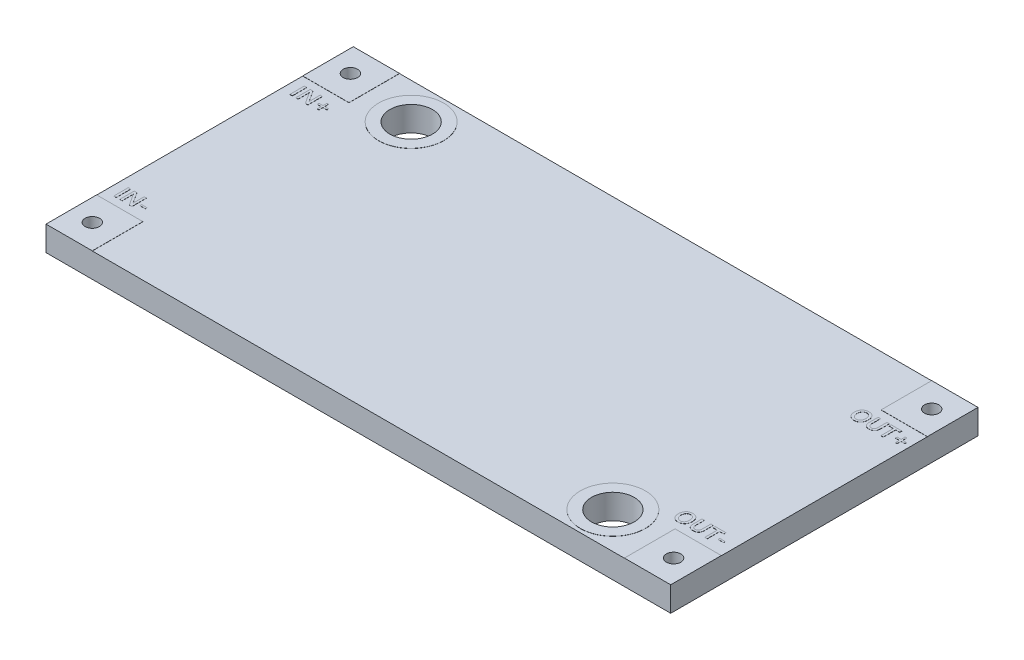
from build123d import *

# Parameters (mm, degrees)
SKETCH1_W           = 43.2
SKETCH1_H           = 21.25
BOSS_EXTRUDE1_DEPTH = 1.7
SKETCH2_R           = 1.475
SKETCH2_R_2         = 0.5
CUT_EXTRUDE1_DEPTH  = 25.131734811
SKETCH3_R           = 2.25
SKETCH3_R_2         = 1.475
SKETCH3_W           = 3.2
SKETCH3_H           = 3.5
SKETCH3_R_3         = 0.5
BOSS_EXTRUDE2_DEPTH = 0.01
SKETCH4_W           = 0.170024671
SKETCH4_H           = 1
SKETCH4_W_2         = 0.37890625
SKETCH4_H_2         = 0.118421053
BOSS_EXTRUDE3_DEPTH = 0.01


with BuildPart() as part:
    # Sketch1 → Boss-Extrude1 (new body)
    with BuildSketch(Plane(origin=(0, 0, 0), x_dir=(1, 0, 0), z_dir=(0, 1, 0))):
        Rectangle(SKETCH1_W, SKETCH1_H)
    extrude(amount=BOSS_EXTRUDE1_DEPTH)

    # Sketch2 → Cut-Extrude1 (cut, through all)
    with BuildSketch(Plane(origin=(0, 0, 0), x_dir=(1, 0, 0), z_dir=(0, 1, 0))):
        with Locations(Location((-15.1, 8.125, 0), (0, 0, 270))):
            Circle(SKETCH2_R)
        with Locations(Location((-20.1, 8.925, 0), (0, 0, 270))):
            Circle(SKETCH2_R_2)
        with Locations(Location((15.1, -8.125, 0), (0, 0, 270))):
            Circle(SKETCH2_R)
        with Locations(Location((20.1, -8.925, 0), (0, 0, 270))):
            Circle(SKETCH2_R_2)
        with Locations(Location((20.1, 8.925, 0), (0, 0, 90))):
            Circle(SKETCH2_R_2)
        with Locations(Location((-20.1, -8.925, 0), (0, 0, 90))):
            Circle(SKETCH2_R_2)
    extrude(amount=CUT_EXTRUDE1_DEPTH, mode=Mode.SUBTRACT)

    # Sketch3 → Boss-Extrude2 (add)
    with BuildSketch(Plane(origin=(0, 1.7, 0), x_dir=(1, 0, 0), z_dir=(0, 1, 0))):
        with Locations(Location((-15.1, 8.125, 0), (0, 0, 90))):
            Circle(SKETCH3_R)
        with Locations(Location((-15.1, 8.125, 0), (0, 0, 270))):
            Circle(SKETCH3_R_2, mode=Mode.SUBTRACT)
        with Locations(Location((15.1, -8.125, 0), (0, 0, 90))):
            Circle(SKETCH3_R)
        with Locations(Location((15.1, -8.125, 0), (0, 0, 270))):
            Circle(SKETCH3_R_2, mode=Mode.SUBTRACT)
        with Locations((-20, 8.875)):
            Rectangle(SKETCH3_W, SKETCH3_H)
        with Locations(Location((-20.1, 8.925, 0), (0, 0, 270))):
            Circle(SKETCH3_R_3, mode=Mode.SUBTRACT)
        with Locations((-20, -8.875)):
            Rectangle(SKETCH3_W, SKETCH3_H)
        with Locations(Location((-20.1, -8.925, 0), (0, 0, 90))):
            Circle(SKETCH3_R_3, mode=Mode.SUBTRACT)
        with Locations((20, -8.875)):
            Rectangle(SKETCH3_W, SKETCH3_H)
        with Locations(Location((20.1, -8.925, 0), (0, 0, 270))):
            Circle(SKETCH3_R_3, mode=Mode.SUBTRACT)
        with Locations((20, 8.875)):
            Rectangle(SKETCH3_W, SKETCH3_H)
        with Locations(Location((20.1, 8.925, 0), (0, 0, 90))):
            Circle(SKETCH3_R_3, mode=Mode.SUBTRACT)
    extrude(amount=BOSS_EXTRUDE2_DEPTH)

    # Sketch4 → Boss-Extrude3 (add)
    with BuildSketch(Plane(origin=(0, 1.7, 0), x_dir=(1, 0, 0), z_dir=(0, 1, 0))):
        with Locations((-20.852438923, 6.075899594)):
            Rectangle(SKETCH4_W, SKETCH4_H)
        with BuildLine():
            Line((-19.685189745, 5.575899594), (-19.865494021, 5.575899594))
            Line((-19.865494021, 5.575899594), (-20.340822969, 6.31089137))
            add(Edge.make_bspline(
                [(-20.340822969, 6.31089137), (-20.34654146, 6.320295921), (-20.357860845, 6.338911621), (-20.366405755, 6.358952171), (-20.370633824, 6.368868344)],
                knots=[0, 0, 0, 0, 1.010389057, 2, 2, 2, 2], degree=3))
            Line((-20.370633824, 6.368868344), (-20.374745666, 6.368868344))
            add(Edge.make_bspline(
                [(-20.374745666, 6.368868344), (-20.374325341, 6.365785885), (-20.373392772, 6.358946868), (-20.372063704, 6.347515569), (-20.371450169, 6.333779731), (-20.3705252, 6.317752766), (-20.369949118, 6.299449662), (-20.369617758, 6.278819113), (-20.369072437, 6.255932042), (-20.369152789, 6.23989393), (-20.369194679, 6.231532818)],
                knots=[0, 0, 0, 0, 0.542850591, 1.204416297, 2.006997007, 2.940909611, 4.005733812, 5.201725499, 6.541181877, 8, 8, 8, 8], degree=3))
            Line((-20.369194679, 6.231532818), (-20.369194679, 5.575899594))
            Line((-20.369194679, 5.575899594), (-20.528939745, 5.575899594))
            Line((-20.528939745, 5.575899594), (-20.528939745, 6.575899594))
            Line((-20.528939745, 6.575899594), (-20.336711126, 6.575899594))
            Line((-20.336711126, 6.575899594), (-19.877212771, 5.858383147))
            add(Edge.make_bspline(
                [(-19.877212771, 5.858383147), (-19.872803757, 5.851544578), (-19.86472599, 5.839015618), (-19.85411523, 5.821873507), (-19.845964808, 5.808266036), (-19.841625663, 5.800280254), (-19.839795008, 5.796911107)],
                knots=[0, 0, 0, 0, 1.356381881, 2.48503099, 3.360844982, 4, 4, 4, 4], degree=3))
            Line((-19.839795008, 5.796911107), (-19.837122311, 5.796911107))
            add(Edge.make_bspline(
                [(-19.837122311, 5.796911107), (-19.83771686, 5.8004688), (-19.839004079, 5.808171316), (-19.840032502, 5.820758925), (-19.841330637, 5.835000209), (-19.842409475, 5.85096876), (-19.842850435, 5.868663676), (-19.843639937, 5.888119478), (-19.843671104, 5.909302235), (-19.843826334, 5.923967309), (-19.84390685, 5.931573936)],
                knots=[0, 0, 0, 0, 0.641182925, 1.388181035, 2.244403229, 3.184783092, 4.233507647, 5.391855368, 6.647181581, 8, 8, 8, 8], degree=3))
            Line((-19.84390685, 5.931573936), (-19.84390685, 6.575899594))
            Line((-19.84390685, 6.575899594), (-19.685189745, 6.575899594))
            Line((-19.685189745, 6.575899594), (-19.685189745, 5.575899594))
        make_face()
        Polygon((-18.731653561, 5.931162752), (-19.005707837, 5.931162752), (-19.005707837, 5.654846962), (-19.12022264, 5.654846962), (-19.12022264, 5.931162752), (-19.394276916, 5.931162752), (-19.394276916, 6.049583805), (-19.12022264, 6.049583805), (-19.12022264, 6.325899594), (-19.005707837, 6.325899594), (-19.005707837, 6.049583805), (-18.731653561, 6.049583805), align=None)
        with Locations((-20.852438923, -6.097777607)):
            Rectangle(SKETCH4_W, SKETCH4_H)
        with BuildLine():
            Line((-19.685189745, -6.597777607), (-19.865494021, -6.597777607))
            Line((-19.865494021, -6.597777607), (-20.340822969, -5.862785831))
            add(Edge.make_bspline(
                [(-20.340822969, -5.862785831), (-20.34654146, -5.853381281), (-20.357860845, -5.83476558), (-20.366405755, -5.814725031), (-20.370633824, -5.804808857)],
                knots=[0, 0, 0, 0, 1.010389057, 2, 2, 2, 2], degree=3))
            Line((-20.370633824, -5.804808857), (-20.374745666, -5.804808857))
            add(Edge.make_bspline(
                [(-20.374745666, -5.804808857), (-20.374325341, -5.807891316), (-20.373392772, -5.814730333), (-20.372063704, -5.826161632), (-20.371450169, -5.83989747), (-20.3705252, -5.855924436), (-20.369949118, -5.87422754), (-20.369617758, -5.894858089), (-20.369072437, -5.917745159), (-20.369152789, -5.933783271), (-20.369194679, -5.942144384)],
                knots=[0, 0, 0, 0, 0.542850591, 1.204416297, 2.006997007, 2.940909611, 4.005733812, 5.201725499, 6.541181877, 8, 8, 8, 8], degree=3))
            Line((-20.369194679, -5.942144384), (-20.369194679, -6.597777607))
            Line((-20.369194679, -6.597777607), (-20.528939745, -6.597777607))
            Line((-20.528939745, -6.597777607), (-20.528939745, -5.597777607))
            Line((-20.528939745, -5.597777607), (-20.336711126, -5.597777607))
            Line((-20.336711126, -5.597777607), (-19.877212771, -6.315294055))
            add(Edge.make_bspline(
                [(-19.877212771, -6.315294055), (-19.872803757, -6.322132623), (-19.86472599, -6.334661583), (-19.85411523, -6.351803695), (-19.845964808, -6.365411166), (-19.841625663, -6.373396948), (-19.839795008, -6.376766094)],
                knots=[0, 0, 0, 0, 1.356381881, 2.48503099, 3.360844982, 4, 4, 4, 4], degree=3))
            Line((-19.839795008, -6.376766094), (-19.837122311, -6.376766094))
            add(Edge.make_bspline(
                [(-19.837122311, -6.376766094), (-19.83771686, -6.373208401), (-19.839004079, -6.365505886), (-19.840032502, -6.352918277), (-19.841330637, -6.338676992), (-19.842409475, -6.322708442), (-19.842850435, -6.305013525), (-19.843639937, -6.285557723), (-19.843671104, -6.264374967), (-19.843826334, -6.249709892), (-19.84390685, -6.242103265)],
                knots=[0, 0, 0, 0, 0.641182925, 1.388181035, 2.244403229, 3.184783092, 4.233507647, 5.391855368, 6.647181581, 8, 8, 8, 8], degree=3))
            Line((-19.84390685, -6.242103265), (-19.84390685, -5.597777607))
            Line((-19.84390685, -5.597777607), (-19.685189745, -5.597777607))
            Line((-19.685189745, -5.597777607), (-19.685189745, -6.597777607))
        make_face()
        with Locations((-19.27020208, -6.209619713)):
            Rectangle(SKETCH4_W_2, SKETCH4_H_2)
        with BuildLine():
            add(Edge.make_bspline(
                [(18.082538877, 5.562741699), (18.065044998, 5.563194363), (18.030828975, 5.564079722), (17.980815608, 5.570465796), (17.933499786, 5.581360524), (17.888833922, 5.596613073), (17.84675845, 5.616178356), (17.8075888, 5.640458261), (17.770862125, 5.668768002), (17.737315693, 5.701416599), (17.707239746, 5.737566169), (17.680667293, 5.776359769), (17.658435613, 5.817987884), (17.640031245, 5.862161287), (17.625885134, 5.909016789), (17.61584568, 5.958428037), (17.609819326, 6.010440216), (17.609044893, 6.046003971), (17.608649075, 6.064180844)],
                knots=[0, 0, 0, 0, 1.080688534, 2.113702916, 3.108931422, 4.075669577, 5.024646271, 5.969410339, 6.917101566, 7.884256872, 8.855186167, 9.818171139, 10.784287868, 11.765612141, 12.770163835, 13.803152185, 14.877176389, 16, 16, 16, 16], degree=3))
            add(Edge.make_bspline(
                [(17.608649075, 6.064180844), (17.60902151, 6.083661091), (17.609748676, 6.121695593), (17.616070295, 6.177248847), (17.626175781, 6.229769327), (17.64064918, 6.279255719), (17.659134947, 6.325816033), (17.682007984, 6.369262503), (17.708947669, 6.409707591), (17.739745804, 6.446846772), (17.773991489, 6.480446284), (17.811624929, 6.509586269), (17.8522784, 6.534202395), (17.895794961, 6.554512682), (17.942463245, 6.569754539), (17.991816929, 6.581232651), (18.044261223, 6.587753142), (18.080191318, 6.588616003), (18.098575062, 6.589057489)],
                knots=[0, 0, 0, 0, 1.15222704, 2.249682958, 3.303300419, 4.313064797, 5.295631801, 6.262317599, 7.212562825, 8.165710149, 9.111907019, 10.045395757, 10.97510803, 11.91840756, 12.880046247, 13.874430042, 14.912445645, 16, 16, 16, 16], degree=3))
            add(Edge.make_bspline(
                [(18.098575062, 6.589057489), (18.115657255, 6.58860247), (18.14905297, 6.587712909), (18.197853716, 6.58136688), (18.243997991, 6.570303312), (18.287827157, 6.555465072), (18.328960585, 6.53576357), (18.367478907, 6.511730906), (18.40342934, 6.483361218), (18.436621527, 6.450952989), (18.466476029, 6.415054604), (18.492881339, 6.37641967), (18.514914443, 6.334875364), (18.53277228, 6.290663628), (18.546833159, 6.243868595), (18.556818224, 6.194462892), (18.562877003, 6.142319589), (18.563643239, 6.106686506), (18.564035588, 6.088440712)],
                knots=[0, 0, 0, 0, 1.065808981, 2.083658202, 3.063810198, 4.022601448, 4.965556375, 5.902929278, 6.849938112, 7.817604304, 8.792171557, 9.758797867, 10.732511031, 11.720347187, 12.729563492, 13.777019773, 14.861730821, 16, 16, 16, 16], degree=3))
            add(Edge.make_bspline(
                [(18.564035588, 6.088440712), (18.563661485, 6.068687355), (18.562932134, 6.030176222), (18.556660588, 5.973994363), (18.54639752, 5.920989541), (18.532378357, 5.8709808), (18.513803091, 5.824277725), (18.491027533, 5.780871668), (18.464427597, 5.740413706), (18.433616397, 5.703569218), (18.399487465, 5.67045022), (18.362524502, 5.641383389), (18.322606881, 5.617032475), (18.279895722, 5.597177221), (18.234450178, 5.581779097), (18.186256246, 5.570659835), (18.135286827, 5.564028952), (18.100376708, 5.563177011), (18.082538877, 5.562741699)],
                knots=[0, 0, 0, 0, 1.177234893, 2.295136328, 3.364707178, 4.392715417, 5.386476074, 6.354925964, 7.310067309, 8.267250732, 9.211947684, 10.14028609, 11.064408358, 11.992845631, 12.942370588, 13.919441291, 14.936908422, 16, 16, 16, 16], degree=3))
        make_face()
        with BuildLine():
            add(Edge.make_bspline(
                [(18.090145785, 6.444320647), (18.079027753, 6.443995901), (18.057168711, 6.443357421), (18.025159802, 6.438586548), (17.994769235, 6.430536021), (17.965996639, 6.419392074), (17.938801294, 6.405070541), (17.913177567, 6.387509084), (17.889287751, 6.366567328), (17.867174085, 6.342800187), (17.847220399, 6.316409333), (17.82969933, 6.28787367), (17.81517933, 6.257180426), (17.802804982, 6.22474567), (17.793786127, 6.190025026), (17.786902111, 6.153430984), (17.783065361, 6.114769171), (17.782472364, 6.088380086), (17.782168812, 6.074871633)],
                knots=[0, 0, 0, 0, 0.988164096, 1.942818717, 2.869377484, 3.777873969, 4.679912813, 5.595814758, 6.532869555, 7.498464472, 8.476908715, 9.469532548, 10.469588381, 11.491398077, 12.550994941, 13.653913012, 14.799048759, 16, 16, 16, 16], degree=3))
            add(Edge.make_bspline(
                [(17.782168812, 6.074871633), (17.782378915, 6.061429864), (17.782789346, 6.035171753), (17.78677543, 5.996747958), (17.793330103, 5.960328606), (17.802305788, 5.925827415), (17.814019847, 5.89338011), (17.828548153, 5.863026801), (17.845369286, 5.834481019), (17.864860493, 5.808276182), (17.886398449, 5.784628863), (17.909667641, 5.763876534), (17.934736556, 5.746557285), (17.961298848, 5.732161203), (17.989534538, 5.721041707), (18.019364385, 5.713297834), (18.050716429, 5.708398222), (18.072172129, 5.707789934), (18.083155654, 5.707478541)],
                knots=[0, 0, 0, 0, 1.209576796, 2.362873517, 3.472383614, 4.537664675, 5.56795712, 6.572273746, 7.56245417, 8.545712799, 9.506284641, 10.437062317, 11.345664602, 12.242634409, 13.150985398, 14.06964528, 15.011819787, 16, 16, 16, 16], degree=3))
            add(Edge.make_bspline(
                [(18.083155654, 5.707478541), (18.094752066, 5.707730531), (18.117489057, 5.708224606), (18.150635314, 5.712807811), (18.181840434, 5.720403689), (18.211172317, 5.730950422), (18.238562652, 5.744534178), (18.264120322, 5.761126291), (18.287685831, 5.78082796), (18.309259486, 5.803459959), (18.328539045, 5.828813596), (18.345573208, 5.856500131), (18.359683026, 5.886772442), (18.371549602, 5.919329911), (18.380111738, 5.954477323), (18.386802424, 5.991806843), (18.390708332, 6.031545582), (18.391124716, 6.05882698), (18.391338219, 6.072815712)],
                knots=[0, 0, 0, 0, 1.028528343, 2.016627255, 2.961983855, 3.873731828, 4.776575143, 5.668789617, 6.571141343, 7.495835697, 8.437174697, 9.392452997, 10.374395704, 11.395763051, 12.462046906, 13.579731582, 14.758990046, 16, 16, 16, 16], degree=3))
            add(Edge.make_bspline(
                [(18.391338219, 6.072815712), (18.391105827, 6.087213871), (18.390653507, 6.115237857), (18.387029599, 6.156006274), (18.380514348, 6.194224153), (18.372192655, 6.230035074), (18.3606639, 6.263195046), (18.347080713, 6.293996634), (18.330423513, 6.322033421), (18.311820512, 6.347694121), (18.290709242, 6.370321004), (18.267825576, 6.390303328), (18.242780224, 6.407023859), (18.21581917, 6.420633411), (18.187091484, 6.431417144), (18.156459199, 6.438957789), (18.123937438, 6.443602039), (18.101606519, 6.444076924), (18.090145785, 6.444320647)],
                knots=[0, 0, 0, 0, 1.275930431, 2.483418728, 3.622659341, 4.709777534, 5.737328229, 6.729540964, 7.687827304, 8.621963811, 9.533051901, 10.424350274, 11.308689573, 12.194154331, 13.095493964, 14.02201801, 14.984854798, 16, 16, 16, 16], degree=3))
        make_face(mode=Mode.SUBTRACT)
        with BuildLine():
            add(Edge.make_bspline(
                [(19.516749404, 5.982560778), (19.516411646, 5.965624383), (19.515755385, 5.932717131), (19.511332863, 5.885000437), (19.503575875, 5.840570286), (19.492613111, 5.799469759), (19.47908452, 5.761415595), (19.461798974, 5.726814906), (19.441721941, 5.695354451), (19.418194622, 5.667269857), (19.391559503, 5.642538617), (19.361897045, 5.620982298), (19.329158737, 5.602705742), (19.29313322, 5.588315171), (19.254212416, 5.576664643), (19.21219367, 5.568644374), (19.167092115, 5.563595055), (19.136007101, 5.563032282), (19.11995664, 5.562741699)],
                knots=[0, 0, 0, 0, 1.226853155, 2.383763919, 3.467655837, 4.490011703, 5.462137187, 6.387943758, 7.285775493, 8.159766112, 9.034419151, 9.912222379, 10.810054113, 11.743007316, 12.716842562, 13.748867616, 14.83764852, 16, 16, 16, 16], degree=3))
            add(Edge.make_bspline(
                [(19.11995664, 5.562741699), (19.104592333, 5.563051613), (19.074747085, 5.563653623), (19.031505148, 5.568459261), (18.991188777, 5.576067695), (18.953905028, 5.587305339), (18.919468745, 5.601313217), (18.88803203, 5.618825872), (18.859517761, 5.639309299), (18.834247576, 5.663355511), (18.811598667, 5.690167835), (18.792266776, 5.720436525), (18.775961831, 5.753855057), (18.76268836, 5.790405584), (18.752173971, 5.830027578), (18.744973428, 5.872768112), (18.74030133, 5.918586193), (18.739846213, 5.95020201), (18.739611246, 5.966524594)],
                knots=[0, 0, 0, 0, 1.158846926, 2.251066199, 3.278205435, 4.249804329, 5.184010756, 6.07736631, 6.958474974, 7.825285059, 8.702395332, 9.600153407, 10.527352038, 11.502219312, 12.529306499, 13.615587086, 14.768977538, 16, 16, 16, 16], degree=3))
            Line((18.739611246, 5.966524594), (18.739611246, 6.575899594))
            Line((18.739611246, 6.575899594), (18.904701706, 6.575899594))
            Line((18.904701706, 6.575899594), (18.904701706, 6.000652883))
            add(Edge.make_bspline(
                [(18.904701706, 6.000652883), (18.904832494, 5.988791782), (18.905085361, 5.965859347), (18.907794079, 5.932554037), (18.912270898, 5.901585907), (18.918358355, 5.872825135), (18.926327228, 5.846374542), (18.936246874, 5.822251974), (18.947631837, 5.800251077), (18.961231875, 5.780814212), (18.97614746, 5.763308324), (18.993318524, 5.748432643), (19.01204245, 5.735516783), (19.032811543, 5.725294455), (19.055218459, 5.717216082), (19.079347741, 5.711476317), (19.105271959, 5.708242551), (19.123100073, 5.707738452), (19.132292167, 5.707478541)],
                knots=[0, 0, 0, 0, 1.343123546, 2.596815513, 3.781197858, 4.884908217, 5.923490635, 6.905054976, 7.835546472, 8.72258405, 9.586361395, 10.433341515, 11.288004071, 12.15578242, 13.04702078, 13.980776091, 14.958897414, 16, 16, 16, 16], degree=3))
            add(Edge.make_bspline(
                [(19.132292167, 5.707478541), (19.141143849, 5.707647559), (19.158364259, 5.707976373), (19.183364407, 5.711340795), (19.206701879, 5.716776964), (19.22824198, 5.724708847), (19.248166731, 5.734505433), (19.266232448, 5.746815818), (19.282614926, 5.761318407), (19.297206908, 5.77811642), (19.310311552, 5.796931718), (19.321358551, 5.81813398), (19.330822375, 5.841390079), (19.338398767, 5.86695466), (19.344273767, 5.894669401), (19.34851486, 5.924548313), (19.351292711, 5.956603771), (19.351533998, 5.978716862), (19.351658943, 5.990167686)],
                knots=[0, 0, 0, 0, 1.039273001, 2.021842695, 2.957137814, 3.848510232, 4.71256286, 5.558805872, 6.408526268, 7.275648631, 8.166657446, 9.095765165, 10.077939035, 11.111960622, 12.223548368, 13.403025483, 14.655208456, 16, 16, 16, 16], degree=3))
            Line((19.351658943, 5.990167686), (19.351658943, 6.575899594))
            Line((19.351658943, 6.575899594), (19.516749404, 6.575899594))
            Line((19.516749404, 6.575899594), (19.516749404, 5.982560778))
        make_face()
        Polygon((20.389693483, 6.431162752), (20.103920456, 6.431162752), (20.103920456, 5.575899594), (19.938829996, 5.575899594), (19.938829996, 6.431162752), (19.653673746, 6.431162752), (19.653673746, 6.575899594), (20.389693483, 6.575899594), align=None)
        Polygon((21.245984601, 5.931162752), (20.971930325, 5.931162752), (20.971930325, 5.654846962), (20.857415522, 5.654846962), (20.857415522, 5.931162752), (20.583361246, 5.931162752), (20.583361246, 6.049583805), (20.857415522, 6.049583805), (20.857415522, 6.325899594), (20.971930325, 6.325899594), (20.971930325, 6.049583805), (21.245984601, 6.049583805), align=None)
        with BuildLine():
            add(Edge.make_bspline(
                [(18.082538877, -6.610935502), (18.065044998, -6.610482838), (18.030828975, -6.60959748), (17.980815608, -6.603211406), (17.933499786, -6.592316677), (17.888833922, -6.577064128), (17.84675845, -6.557498846), (17.8075888, -6.53321894), (17.770862125, -6.504909199), (17.737315693, -6.472260602), (17.707239746, -6.436111032), (17.680667293, -6.397317433), (17.658435613, -6.355689317), (17.640031245, -6.311515914), (17.625885134, -6.264660412), (17.61584568, -6.215249164), (17.609819326, -6.163236985), (17.609044893, -6.12767323), (17.608649075, -6.109496357)],
                knots=[0, 0, 0, 0, 1.080688534, 2.113702916, 3.108931422, 4.075669577, 5.024646271, 5.969410339, 6.917101566, 7.884256872, 8.855186167, 9.818171139, 10.784287868, 11.765612141, 12.770163835, 13.803152185, 14.877176389, 16, 16, 16, 16], degree=3))
            add(Edge.make_bspline(
                [(17.608649075, -6.109496357), (17.60902151, -6.09001611), (17.609748676, -6.051981609), (17.616070295, -5.996428354), (17.626175781, -5.943907874), (17.64064918, -5.894421483), (17.659134947, -5.847861168), (17.682007984, -5.804414698), (17.708947669, -5.76396961), (17.739745804, -5.726830429), (17.773991489, -5.693230918), (17.811624929, -5.664090932), (17.8522784, -5.639474806), (17.895794961, -5.619164519), (17.942463245, -5.603922662), (17.991816929, -5.59244455), (18.044261223, -5.58592406), (18.080191318, -5.585061198), (18.098575062, -5.584619713)],
                knots=[0, 0, 0, 0, 1.15222704, 2.249682958, 3.303300419, 4.313064797, 5.295631801, 6.262317599, 7.212562825, 8.165710149, 9.111907019, 10.045395757, 10.97510803, 11.91840756, 12.880046247, 13.874430042, 14.912445645, 16, 16, 16, 16], degree=3))
            add(Edge.make_bspline(
                [(18.098575062, -5.584619713), (18.115657255, -5.585074731), (18.14905297, -5.585964292), (18.197853716, -5.592310321), (18.243997991, -5.60337389), (18.287827157, -5.618212129), (18.328960585, -5.637913631), (18.367478907, -5.661946295), (18.40342934, -5.690315983), (18.436621527, -5.722724212), (18.466476029, -5.758622598), (18.492881339, -5.797257531), (18.514914443, -5.838801837), (18.53277228, -5.883013573), (18.546833159, -5.929808606), (18.556818224, -5.97921431), (18.562877003, -6.031357613), (18.563643239, -6.066990695), (18.564035588, -6.085236489)],
                knots=[0, 0, 0, 0, 1.065808981, 2.083658202, 3.063810198, 4.022601448, 4.965556375, 5.902929278, 6.849938112, 7.817604304, 8.792171557, 9.758797867, 10.732511031, 11.720347187, 12.729563492, 13.777019773, 14.861730821, 16, 16, 16, 16], degree=3))
            add(Edge.make_bspline(
                [(18.564035588, -6.085236489), (18.563661485, -6.104989847), (18.562932134, -6.143500979), (18.556660588, -6.199682838), (18.54639752, -6.252687661), (18.532378357, -6.302696401), (18.513803091, -6.349399476), (18.491027533, -6.392805534), (18.464427597, -6.433263496), (18.433616397, -6.470107983), (18.399487465, -6.503226981), (18.362524502, -6.532293812), (18.322606881, -6.556644726), (18.279895722, -6.57649998), (18.234450178, -6.591898104), (18.186256246, -6.603017366), (18.135286827, -6.609648249), (18.100376708, -6.61050019), (18.082538877, -6.610935502)],
                knots=[0, 0, 0, 0, 1.177234893, 2.295136328, 3.364707178, 4.392715417, 5.386476074, 6.354925964, 7.310067309, 8.267250732, 9.211947684, 10.14028609, 11.064408358, 11.992845631, 12.942370588, 13.919441291, 14.936908422, 16, 16, 16, 16], degree=3))
        make_face()
        with BuildLine():
            add(Edge.make_bspline(
                [(18.090145785, -5.729356555), (18.079027753, -5.729681301), (18.057168711, -5.73031978), (18.025159802, -5.735090653), (17.994769235, -5.74314118), (17.965996639, -5.754285127), (17.938801294, -5.768606661), (17.913177567, -5.786168118), (17.889287751, -5.807109873), (17.867174085, -5.830877015), (17.847220399, -5.857267868), (17.82969933, -5.885803531), (17.81517933, -5.916496775), (17.802804982, -5.948931531), (17.793786127, -5.983652175), (17.786902111, -6.020246217), (17.783065361, -6.05890803), (17.782472364, -6.085297115), (17.782168812, -6.098805568)],
                knots=[0, 0, 0, 0, 0.988164096, 1.942818717, 2.869377484, 3.777873969, 4.679912813, 5.595814758, 6.532869555, 7.498464472, 8.476908715, 9.469532548, 10.469588381, 11.491398077, 12.550994941, 13.653913012, 14.799048759, 16, 16, 16, 16], degree=3))
            add(Edge.make_bspline(
                [(17.782168812, -6.098805568), (17.782378915, -6.112247337), (17.782789346, -6.138505448), (17.78677543, -6.176929243), (17.793330103, -6.213348595), (17.802305788, -6.247849787), (17.814019847, -6.280297091), (17.828548153, -6.3106504), (17.845369286, -6.339196182), (17.864860493, -6.365401019), (17.886398449, -6.389048338), (17.909667641, -6.409800668), (17.934736556, -6.427119916), (17.961298848, -6.441515998), (17.989534538, -6.452635494), (18.019364385, -6.460379368), (18.050716429, -6.465278979), (18.072172129, -6.465887267), (18.083155654, -6.46619866)],
                knots=[0, 0, 0, 0, 1.209576796, 2.362873517, 3.472383614, 4.537664675, 5.56795712, 6.572273746, 7.56245417, 8.545712799, 9.506284641, 10.437062317, 11.345664602, 12.242634409, 13.150985398, 14.06964528, 15.011819787, 16, 16, 16, 16], degree=3))
            add(Edge.make_bspline(
                [(18.083155654, -6.46619866), (18.094752066, -6.46594667), (18.117489057, -6.465452596), (18.150635314, -6.460869391), (18.181840434, -6.453273512), (18.211172317, -6.442726779), (18.238562652, -6.429143023), (18.264120322, -6.41255091), (18.287685831, -6.392849241), (18.309259486, -6.370217242), (18.328539045, -6.344863606), (18.345573208, -6.31717707), (18.359683026, -6.286904759), (18.371549602, -6.25434729), (18.380111738, -6.219199879), (18.386802424, -6.181870358), (18.390708332, -6.14213162), (18.391124716, -6.114850221), (18.391338219, -6.100861489)],
                knots=[0, 0, 0, 0, 1.028528343, 2.016627255, 2.961983855, 3.873731828, 4.776575143, 5.668789617, 6.571141343, 7.495835697, 8.437174697, 9.392452997, 10.374395704, 11.395763051, 12.462046906, 13.579731582, 14.758990046, 16, 16, 16, 16], degree=3))
            add(Edge.make_bspline(
                [(18.391338219, -6.100861489), (18.391105827, -6.08646333), (18.390653507, -6.058439345), (18.387029599, -6.017670927), (18.380514348, -5.979453048), (18.372192655, -5.943642127), (18.3606639, -5.910482155), (18.347080713, -5.879680567), (18.330423513, -5.85164378), (18.311820512, -5.82598308), (18.290709242, -5.803356198), (18.267825576, -5.783373873), (18.242780224, -5.766653342), (18.21581917, -5.75304379), (18.187091484, -5.742260057), (18.156459199, -5.734719413), (18.123937438, -5.730075163), (18.101606519, -5.729600277), (18.090145785, -5.729356555)],
                knots=[0, 0, 0, 0, 1.275930431, 2.483418728, 3.622659341, 4.709777534, 5.737328229, 6.729540964, 7.687827304, 8.621963811, 9.533051901, 10.424350274, 11.308689573, 12.194154331, 13.095493964, 14.02201801, 14.984854798, 16, 16, 16, 16], degree=3))
        make_face(mode=Mode.SUBTRACT)
        with BuildLine():
            add(Edge.make_bspline(
                [(19.516749404, -6.191116423), (19.516411646, -6.208052818), (19.515755385, -6.240960071), (19.511332863, -6.288676765), (19.503575875, -6.333106915), (19.492613111, -6.374207443), (19.47908452, -6.412261607), (19.461798974, -6.446862296), (19.441721941, -6.47832275), (19.418194622, -6.506407345), (19.391559503, -6.531138584), (19.361897045, -6.552694903), (19.329158737, -6.570971459), (19.29313322, -6.58536203), (19.254212416, -6.597012558), (19.21219367, -6.605032827), (19.167092115, -6.610082146), (19.136007101, -6.610644919), (19.11995664, -6.610935502)],
                knots=[0, 0, 0, 0, 1.226853155, 2.383763919, 3.467655837, 4.490011703, 5.462137187, 6.387943758, 7.285775493, 8.159766112, 9.034419151, 9.912222379, 10.810054113, 11.743007316, 12.716842562, 13.748867616, 14.83764852, 16, 16, 16, 16], degree=3))
            add(Edge.make_bspline(
                [(19.11995664, -6.610935502), (19.104592333, -6.610625588), (19.074747085, -6.610023578), (19.031505148, -6.60521794), (18.991188777, -6.597609506), (18.953905028, -6.586371863), (18.919468745, -6.572363985), (18.88803203, -6.554851329), (18.859517761, -6.534367902), (18.834247576, -6.51032169), (18.811598667, -6.483509367), (18.792266776, -6.453240676), (18.775961831, -6.419822144), (18.76268836, -6.383271618), (18.752173971, -6.343649623), (18.744973428, -6.300909089), (18.74030133, -6.255091008), (18.739846213, -6.223475191), (18.739611246, -6.207152607)],
                knots=[0, 0, 0, 0, 1.158846926, 2.251066199, 3.278205435, 4.249804329, 5.184010756, 6.07736631, 6.958474974, 7.825285059, 8.702395332, 9.600153407, 10.527352038, 11.502219312, 12.529306499, 13.615587086, 14.768977538, 16, 16, 16, 16], degree=3))
            Line((18.739611246, -6.207152607), (18.739611246, -5.597777607))
            Line((18.739611246, -5.597777607), (18.904701706, -5.597777607))
            Line((18.904701706, -5.597777607), (18.904701706, -6.173024318))
            add(Edge.make_bspline(
                [(18.904701706, -6.173024318), (18.904832494, -6.184885419), (18.905085361, -6.207817854), (18.907794079, -6.241123164), (18.912270898, -6.272091294), (18.918358355, -6.300852066), (18.926327228, -6.327302659), (18.936246874, -6.351425227), (18.947631837, -6.373426124), (18.961231875, -6.39286299), (18.97614746, -6.410368877), (18.993318524, -6.425244558), (19.01204245, -6.438160418), (19.032811543, -6.448382746), (19.055218459, -6.456461119), (19.079347741, -6.462200884), (19.105271959, -6.46543465), (19.123100073, -6.465938749), (19.132292167, -6.46619866)],
                knots=[0, 0, 0, 0, 1.343123546, 2.596815513, 3.781197858, 4.884908217, 5.923490635, 6.905054976, 7.835546472, 8.72258405, 9.586361395, 10.433341515, 11.288004071, 12.15578242, 13.04702078, 13.980776091, 14.958897414, 16, 16, 16, 16], degree=3))
            add(Edge.make_bspline(
                [(19.132292167, -6.46619866), (19.141143849, -6.466029642), (19.158364259, -6.465700828), (19.183364407, -6.462336406), (19.206701879, -6.456900238), (19.22824198, -6.448968354), (19.248166731, -6.439171768), (19.266232448, -6.426861383), (19.282614926, -6.412358794), (19.297206908, -6.395560782), (19.310311552, -6.376745483), (19.321358551, -6.355543221), (19.330822375, -6.332287123), (19.338398767, -6.306722541), (19.344273767, -6.2790078), (19.34851486, -6.249128888), (19.351292711, -6.21707343), (19.351533998, -6.194960339), (19.351658943, -6.183509515)],
                knots=[0, 0, 0, 0, 1.039273001, 2.021842695, 2.957137814, 3.848510232, 4.71256286, 5.558805872, 6.408526268, 7.275648631, 8.166657446, 9.095765165, 10.077939035, 11.111960622, 12.223548368, 13.403025483, 14.655208456, 16, 16, 16, 16], degree=3))
            Line((19.351658943, -6.183509515), (19.351658943, -5.597777607))
            Line((19.351658943, -5.597777607), (19.516749404, -5.597777607))
            Line((19.516749404, -5.597777607), (19.516749404, -6.191116423))
        make_face()
        Polygon((20.389693483, -5.742514449), (20.103920456, -5.742514449), (20.103920456, -6.597777607), (19.938829996, -6.597777607), (19.938829996, -5.742514449), (19.653673746, -5.742514449), (19.653673746, -5.597777607), (20.389693483, -5.597777607), align=None)
        with Locations((20.707436081, -6.209619713)):
            Rectangle(SKETCH4_W_2, SKETCH4_H_2)
    extrude(amount=BOSS_EXTRUDE3_DEPTH)


solid = part.part
